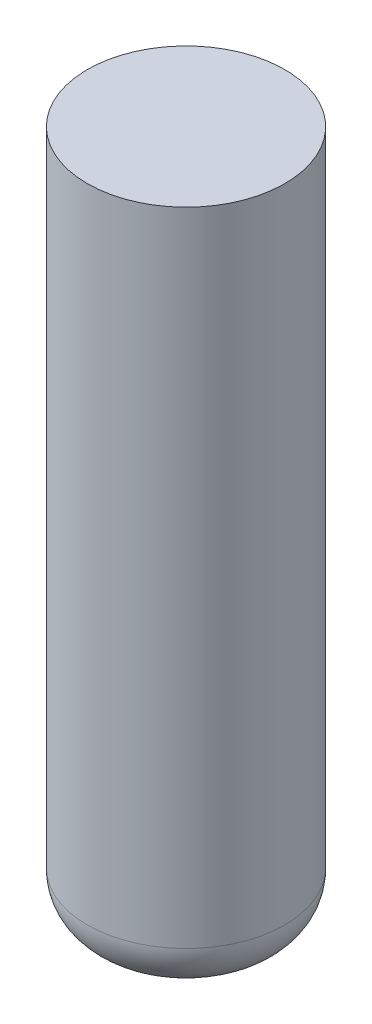
from build123d import *

# Parameters (mm, degrees)
SKETCH1_R           = 1
BOSS_EXTRUDE1_DEPTH = 7
FILLET1_R           = 0.5


with BuildPart() as part:
    # Sketch1 → Boss-Extrude1 (new body)
    with BuildSketch(Plane(origin=(0, 0, 0), x_dir=(1, 0, 0), z_dir=(0, 1, 0))):
        Circle(SKETCH1_R)
    extrude(amount=BOSS_EXTRUDE1_DEPTH)

    # Fillet1
    fillet1_edges = [part.edges().sort_by_distance(p)[0] for p in [
        (-1, 0, 0),
    ]]
    fillet(fillet1_edges, radius=FILLET1_R)


solid = part.part
